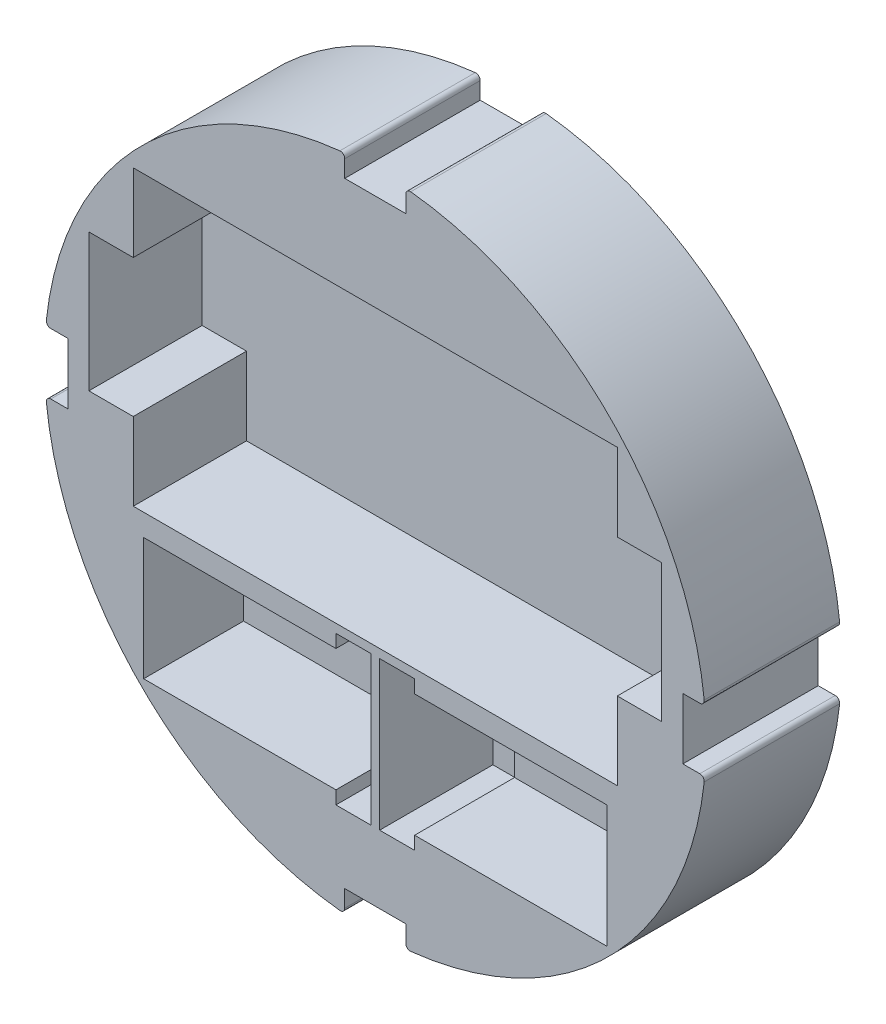
from build123d import *

# Parameters (mm, degrees)
SKETCH2_R           = 75.692
BOSS_EXTRUDE1_DEPTH = 25.908
SKETCH3_R           = 75.692
BOSS_EXTRUDE2_DEPTH = 5.08
SKETCH4_W           = 44
SKETCH4_H           = 28
BOSS_EXTRUDE3_DEPTH = 3.048
CUT_EXTRUDE1_DEPTH  = 31.988
FILLET1_R           = 1.016


with BuildPart() as part:
    # Sketch2 → Boss-Extrude1 (new body)
    with BuildSketch(Plane.XY):
        Circle(SKETCH2_R)
        Polygon((-55.372, 48.26), (55.372, 48.26), (55.372, 30.48), (65.532, 30.48), (65.532, -1.016), (55.372, -1.016), (55.372, -18.796), (-55.372, -18.796), (-55.372, -1.016), (-65.532, -1.016), (-65.532, 30.48), (-55.372, 30.48), align=None, mode=Mode.SUBTRACT)
        Polygon((-53, -23.796), (-9, -23.796), (-9, -20.796), (-1, -20.796), (-1, -54.796), (-9, -54.796), (-9, -51.796), (-53, -51.796), align=None, mode=Mode.SUBTRACT)
        Polygon((53, -23.796), (9, -23.796), (9, -20.796), (1, -20.796), (1, -54.796), (9, -54.796), (9, -51.796), (53, -51.796), align=None, mode=Mode.SUBTRACT)
    extrude(amount=BOSS_EXTRUDE1_DEPTH)

    # Sketch3 → Boss-Extrude2 (add)
    with BuildSketch(Plane(origin=(0, 0, 0), x_dir=(-1, 0, 0), z_dir=(0, 0, -1))):
        Circle(SKETCH3_R)
    extrude(amount=BOSS_EXTRUDE2_DEPTH)

    # Sketch4 → Boss-Extrude3 (add)
    with BuildSketch(Plane.XY):
        with Locations((-31, -37.796)):
            Rectangle(SKETCH4_W, SKETCH4_H)
        with Locations((31, -37.796)):
            Rectangle(SKETCH4_W, SKETCH4_H)
    extrude(amount=BOSS_EXTRUDE3_DEPTH)

    # Sketch7 → Cut-Extrude1 (cut, through all)
    with BuildSketch(Plane.XY.offset(25.908)):
        with BuildLine():
            Line((6.985, 70.358), (-6.985, 70.358))
            Line((-6.985, 70.358), (-6.985, 75.369016439))
            ThreePointArc((-6.985, 75.369016439), (0, 75.692), (6.985, 75.369016439))
            Line((6.985, 75.369016439), (6.985, 70.358))
        make_face()
        with BuildLine():
            Line((70.358, -6.985), (70.358, 6.985))
            Line((70.358, 6.985), (75.369016439, 6.985))
            ThreePointArc((75.369016439, 6.985), (75.692, 0), (75.369016439, -6.985))
            Line((75.369016439, -6.985), (70.358, -6.985))
        make_face()
        with BuildLine():
            Line((-6.985, -70.358), (6.985, -70.358))
            Line((6.985, -70.358), (6.985, -75.369016439))
            ThreePointArc((6.985, -75.369016439), (0, -75.692), (-6.985, -75.369016439))
            Line((-6.985, -75.369016439), (-6.985, -70.358))
        make_face()
        with BuildLine():
            Line((-70.358, 6.985), (-70.358, -6.985))
            Line((-70.358, -6.985), (-75.369016439, -6.985))
            ThreePointArc((-75.369016439, -6.985), (-75.692, 0), (-75.369016439, 6.985))
            Line((-75.369016439, 6.985), (-70.358, 6.985))
        make_face()
    extrude(amount=-CUT_EXTRUDE1_DEPTH, mode=Mode.SUBTRACT)

    # Fillet1
    fillet1_edges = [part.edges().sort_by_distance(p)[0] for p in [
        (6.985, 75.369016439, 10.414),
        (-6.985, 75.369016439, 10.414),
        (75.369016439, -6.985, 10.414),
        (75.369016439, 6.985, 10.414),
        (-6.985, -75.369016439, 10.414),
        (6.985, -75.369016439, 10.414),
        (-75.369016439, 6.985, 10.414),
        (-75.369016439, -6.985, 10.414),
    ]]
    fillet(fillet1_edges, radius=FILLET1_R)


solid = part.part
